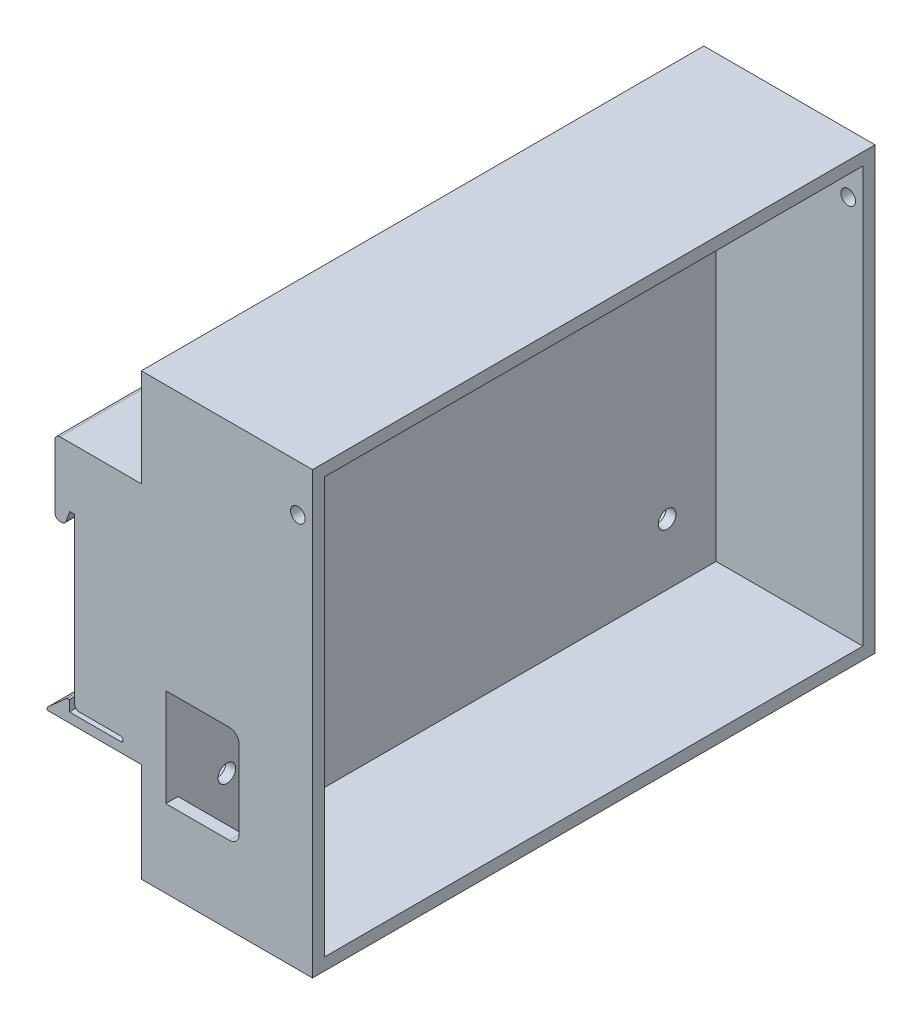
from build123d import *

# Parameters (mm, degrees)
SALIENTE_EXTRUIR1_DEPTH = 115
CROQUIS5_W              = 76.000174198
CROQUIS5_H              = 57.319794633
CORTAR_EXTRUIR2_DEPTH   = 16
CROQUIS6_W              = 76.000174198
CROQUIS6_H              = 7.5
CROQUIS6_W_2            = 76
SALIENTE_EXTRUIR2_DEPTH = 10.35
REDONDEO1_R             = 1
CROQUIS7_W              = 115
CROQUIS7_H              = 90
SALIENTE_EXTRUIR3_DEPTH = 5
CROQUIS14_W             = 115
CROQUIS14_H             = 90
CROQUIS14_W_2           = 110
CROQUIS14_H_2           = 85
SALIENTE_EXTRUIR5_DEPTH = 30
CORTAR_EXTRUIR5_REACH   = 26.29
CROQUIS15_R             = 1.8
CORTAR_EXTRUIR6_REACH   = 4.5
CORTAR_EXTRUIR7_DEPTH   = 3
CROQUIS19_R             = 1.5
CORTAR_EXTRUIR8_DEPTH   = 116


with BuildPart() as part:
    # Croquis1 → Saliente-Extruir1 (new body)
    with BuildSketch(Plane.XY):
        with BuildLine():
            Line((0, 49.71), (-16.64, 49.71))
            ThreePointArc((-16.64, 49.71), (-17.347106781, 49.417106781), (-17.64, 48.71))
            Line((-17.64, 48.71), (-17.64, 35.71))
            ThreePointArc((-17.64, 35.71), (-17.347106781, 35.002893219), (-16.64, 34.71))
            Line((-16.64, 34.71), (-16.322634469, 34.71))
            ThreePointArc((-16.322634469, 34.71), (-15.745851008, 34.89310292), (-15.380289019, 35.375358322))
            Line((-15.380289019, 35.375358322), (-14.64, 37.46))
            Line((-14.64, 37.46), (-13.64, 37.46))
            Line((-13.64, 37.46), (-13.64, 3.96))
            ThreePointArc((-13.64, 3.96), (-13.347106781, 3.252893219), (-12.64, 2.96))
            Line((-12.64, 2.96), (-4.22, 2.96))
            ThreePointArc((-4.22, 2.96), (-3.72, 2.46), (-4.22, 1.96))
            Line((-4.22, 1.96), (-14.72, 1.96))
            Line((-14.72, 1.96), (-14.72, 4.12))
            Line((-14.72, 4.12), (-14.839626167, 4.12))
            ThreePointArc((-14.839626167, 4.12), (-15.19514923, 4.054667509), (-15.504217878, 3.867206703))
            Line((-15.504217878, 3.867206703), (-18.954591711, 0.798323834))
            ThreePointArc((-18.954591711, 0.798323834), (-19.202302502, 0.460634096), (-19.29, 0.051117131))
            Line((-19.29, 0.051117131), (-19.29, 0))
            Line((-19.29, 0), (0, 0))
            Line((0, 0), (0, 49.71))
        make_face()
    extrude(amount=SALIENTE_EXTRUIR1_DEPTH)

    # Croquis5 → Cortar-Extruir2 (cut)
    with BuildSketch(Plane.ZY.offset(19.29)):
        with Locations((53, 24.620732186)):
            Rectangle(CROQUIS5_W, CROQUIS5_H)
    extrude(amount=-CORTAR_EXTRUIR2_DEPTH, mode=Mode.SUBTRACT)

    # Croquis6 → Saliente-Extruir2 (add)
    with BuildSketch(Plane.ZY.offset(3.29)):
        with Locations((53, 45.96)):
            Rectangle(CROQUIS6_W, CROQUIS6_H)
        with Locations((52.999912901, 6.71)):
            Rectangle(CROQUIS6_W_2, CROQUIS6_H)
    extrude(amount=SALIENTE_EXTRUIR2_DEPTH)

    # Redondeo1
    redondeo1_edges = [part.edges().sort_by_distance(p)[0] for p in [
        (-13.64, 2.96, 52.999912901),
    ]]
    fillet(redondeo1_edges, radius=REDONDEO1_R)

    # Croquis7 → Saliente-Extruir3 (add)
    with BuildSketch(Plane(origin=(0, 0, 0), x_dir=(0, 0, -1), z_dir=(1, 0, 0))):
        with Locations((-57.5, 24.71)):
            Rectangle(CROQUIS7_W, CROQUIS7_H)
    extrude(amount=SALIENTE_EXTRUIR3_DEPTH)

    # Croquis14 → Saliente-Extruir5 (add)
    with BuildSketch(Plane(origin=(5, 0, 0), x_dir=(0, 0, -1), z_dir=(1, 0, 0))):
        with Locations((-57.5, 24.71)):
            Rectangle(CROQUIS14_W, CROQUIS14_H)
        with Locations((-57.5, 24.71)):
            Rectangle(CROQUIS14_W_2, CROQUIS14_H_2, mode=Mode.SUBTRACT)
    extrude(amount=SALIENTE_EXTRUIR5_DEPTH)

    # Croquis15 → Cortar-Extruir5 (cut, up to next)
    with BuildSketch(Plane(origin=(5, 0, 0), x_dir=(0, 0, -1), z_dir=(1, 0, 0)), mode=Mode.PRIVATE) as cortar_extruir5_sk1:
        with Locations((-102.5, 54.71)):
            Circle(CROQUIS15_R)
    cortar_extruir5_tool1 = extrude(cortar_extruir5_sk1.sketch, amount=-CORTAR_EXTRUIR5_REACH, mode=Mode.PRIVATE) & part.part
    add(cortar_extruir5_tool1.solids().sort_by_distance((5, 54.71, 102.5))[0], mode=Mode.SUBTRACT)
    # Croquis15 → Cortar-Extruir5 (cut, up to next)
    with BuildSketch(Plane(origin=(5, 0, 0), x_dir=(0, 0, -1), z_dir=(1, 0, 0)), mode=Mode.PRIVATE) as cortar_extruir5_sk2:
        with Locations((-102.5, -5.29)):
            Circle(CROQUIS15_R)
    cortar_extruir5_tool2 = extrude(cortar_extruir5_sk2.sketch, amount=-CORTAR_EXTRUIR5_REACH, mode=Mode.PRIVATE) & part.part
    add(cortar_extruir5_tool2.solids().sort_by_distance((5, -5.29, 102.5))[0], mode=Mode.SUBTRACT)
    # Croquis15 → Cortar-Extruir5 (cut, up to next)
    with BuildSketch(Plane(origin=(5, 0, 0), x_dir=(0, 0, -1), z_dir=(1, 0, 0)), mode=Mode.PRIVATE) as cortar_extruir5_sk3:
        with Locations((-12.5, -5.29)):
            Circle(CROQUIS15_R)
    cortar_extruir5_tool3 = extrude(cortar_extruir5_sk3.sketch, amount=-CORTAR_EXTRUIR5_REACH, mode=Mode.PRIVATE) & part.part
    add(cortar_extruir5_tool3.solids().sort_by_distance((5, -5.29, 12.5))[0], mode=Mode.SUBTRACT)
    # Croquis15 → Cortar-Extruir5 (cut, up to next)
    with BuildSketch(Plane(origin=(5, 0, 0), x_dir=(0, 0, -1), z_dir=(1, 0, 0)), mode=Mode.PRIVATE) as cortar_extruir5_sk4:
        with Locations((-12.5, 54.71)):
            Circle(CROQUIS15_R)
    cortar_extruir5_tool4 = extrude(cortar_extruir5_sk4.sketch, amount=-CORTAR_EXTRUIR5_REACH, mode=Mode.PRIVATE) & part.part
    add(cortar_extruir5_tool4.solids().sort_by_distance((5, 54.71, 12.5))[0], mode=Mode.SUBTRACT)

    # Croquis16 → Cortar-Extruir6 (cut, up to next)
    with BuildSketch(Plane(origin=(0, 0, 112.5), x_dir=(-1, 0, 0), z_dir=(0, 0, -1)), mode=Mode.PRIVATE) as cortar_extruir6_sk1:
        with BuildLine():
            Line((-5, -4.415), (-5, 15.585))
            Line((-5, 15.585), (-18, 15.585))
            ThreePointArc((-18, 15.585), (-19.414213562, 14.999213562), (-20, 13.585))
            Line((-20, 13.585), (-20, -2.415))
            ThreePointArc((-20, -2.415), (-19.414213562, -3.829213562), (-18, -4.415))
            Line((-18, -4.415), (-5, -4.415))
        make_face()
    cortar_extruir6_tool1 = extrude(cortar_extruir6_sk1.sketch, amount=-CORTAR_EXTRUIR6_REACH, mode=Mode.PRIVATE) & part.part
    add(cortar_extruir6_tool1.solids().sort_by_distance((12.459404, 5.585, 112.5))[0], mode=Mode.SUBTRACT)

    # Croquis17 → Cortar-Extruir7 (cut)
    with BuildSketch(Plane.ZY):
        Polygon((12.5, 51.245898385), (15.5, 52.977949192), (15.5, 56.442050808), (12.5, 58.174101615), (9.5, 56.442050808), (9.5, 52.977949192), align=None)
        Polygon((9.5, -3.557949192), (12.5, -1.825898385), (15.5, -3.557949192), (15.5, -7.022050808), (12.5, -8.754101615), (9.5, -7.022050808), align=None)
        Polygon((105.5, 52.977949192), (102.5, 51.245898385), (99.5, 52.977949192), (99.5, 56.442050808), (102.5, 58.174101615), (105.5, 56.442050808), align=None)
        Polygon((102.5, -1.825898385), (99.5, -3.557949192), (99.5, -7.022050808), (102.5, -8.754101615), (105.5, -7.022050808), (105.5, -3.557949192), align=None)
    extrude(amount=-CORTAR_EXTRUIR7_DEPTH, mode=Mode.SUBTRACT)

    # Croquis19 → Cortar-Extruir8 (cut, through all)
    with BuildSketch(Plane(origin=(0, 0, 0), x_dir=(-1, 0, 0), z_dir=(0, 0, -1))):
        with Locations((-32, 60.21)):
            Circle(CROQUIS19_R)
    extrude(amount=-CORTAR_EXTRUIR8_DEPTH, mode=Mode.SUBTRACT)


solid = part.part
